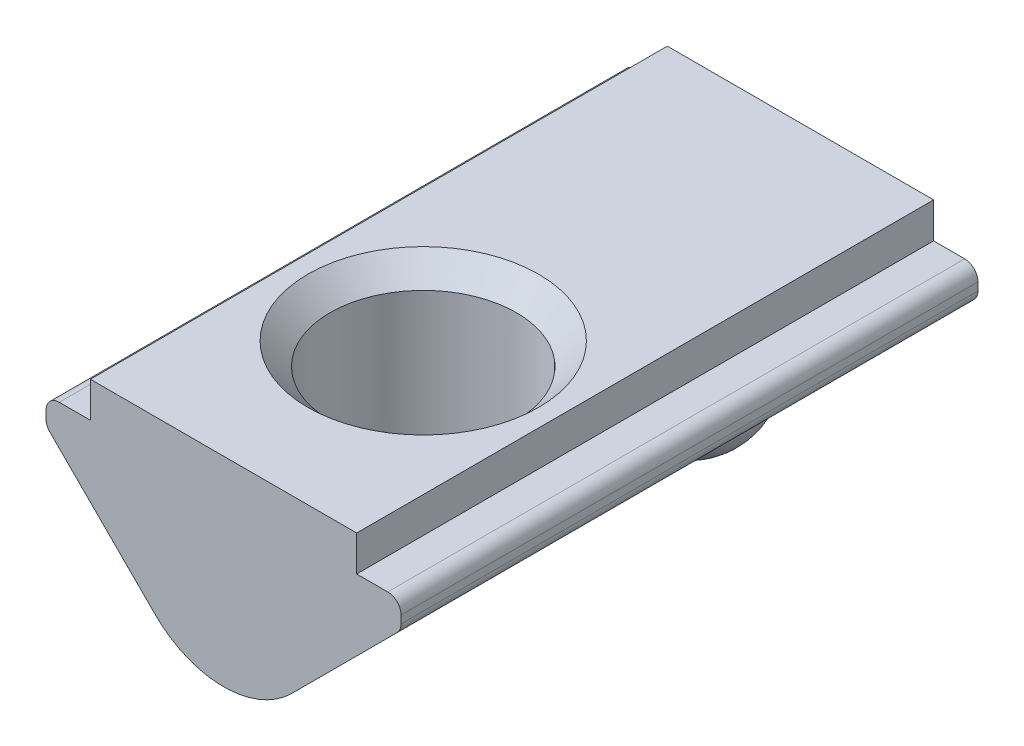
from build123d import *

# Parameters (mm, degrees)
EXTRUDE_1_DEPTH             = 6.5
HOLE_WIZARD_M51_D           = 4.2
HOLE_WIZARD_M51_CSINK_D     = 5.2
HOLE_WIZARD_M51_CSINK_ANGLE = 90
FILLET_1_R                  = 0.3


with BuildPart() as part:
    # Эскиз1 → Бобышка-Вытянуть1 (new body, symmetric)
    with BuildSketch(Plane.XY):
        with BuildLine():
            Line((-3, 0), (3, 0))
            Line((3, 0), (3, -0.8))
            Line((3, -0.8), (4, -0.8))
            Line((4, -0.8), (4, -1.4))
            Line((4, -1.4), (1.536396103, -3.863603897))
            ThreePointArc((1.536396103, -3.863603897), (0, -4.5), (-1.536396103, -3.863603897))
            Line((-1.536396103, -3.863603897), (-4, -1.4))
            Line((-4, -1.4), (-4, -0.8))
            Line((-4, -0.8), (-3, -0.8))
            Line((-3, -0.8), (-3, 0))
        make_face()
    extrude(amount=EXTRUDE_1_DEPTH, both=True)

    # Отверстие обработанное метчиком M51 (through all)
    with Locations(Plane(origin=(0, 0, 0), x_dir=(1, 0, 0), z_dir=(0, 1, 0))):
        with Locations((0, -2)):
            CounterSinkHole(HOLE_WIZARD_M51_D / 2, HOLE_WIZARD_M51_CSINK_D / 2, counter_sink_angle=HOLE_WIZARD_M51_CSINK_ANGLE)

    # Эскиз5 → Повернуть1 (revolve)
    with BuildSketch(Plane(origin=(0, 0, 0), x_dir=(0, 0, -1), z_dir=(1, 0, 0))):
        with BuildLine():
            Line((4, -2), (4, -5))
            ThreePointArc((4, -5), (2.5, -3.5), (4, -2))
        make_face()
    revolve(axis=Axis((0, -2, -4), (0, -1, 0)))

    # Скругление1
    fillet_1_edges = [part.edges().sort_by_distance(p)[0] for p in [
        (4, -0.8, 0),
        (4, -1.4, 0),
        (-4, -1.4, 0),
        (-4, -0.8, 0),
    ]]
    fillet(fillet_1_edges, radius=FILLET_1_R)


solid = part.part
